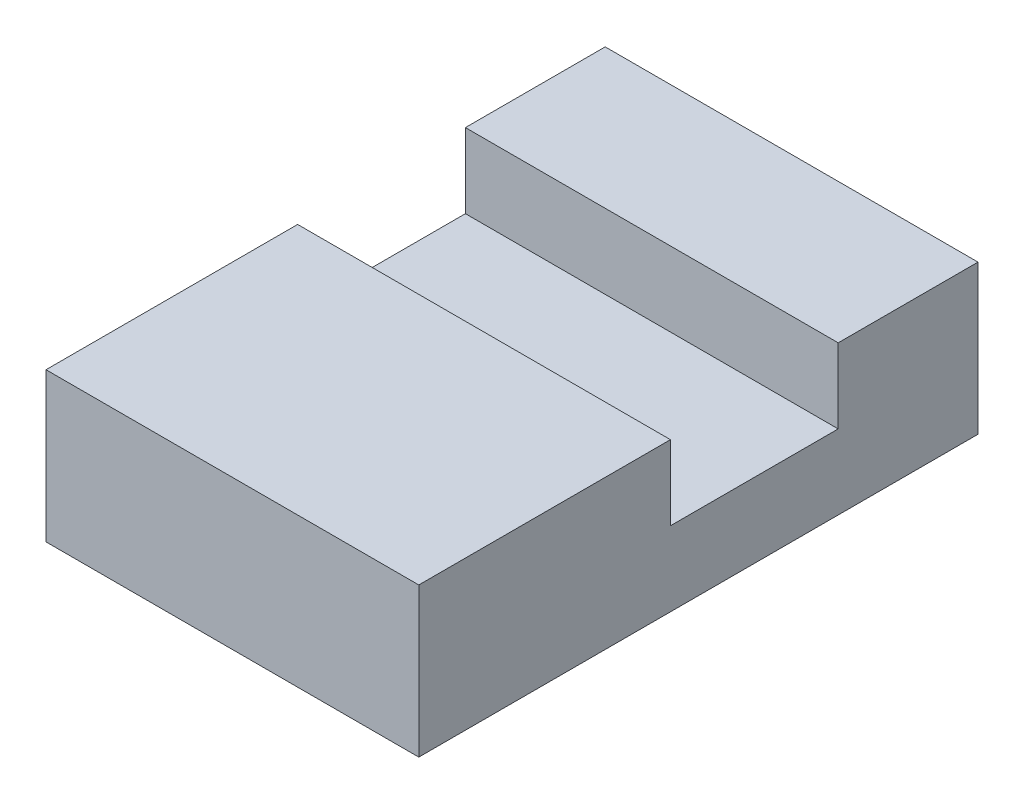
from build123d import *

# Parameters (mm, degrees)
SKETCH1_W           = 20
SKETCH1_H           = 30
BOSS_EXTRUDE1_DEPTH = 8
SKETCH3_W           = 9
SKETCH3_H           = 4
CUT_EXTRUDE1_DEPTH  = 20


with BuildPart() as part:
    # Sketch1 → Boss-Extrude1 (new body)
    with BuildSketch(Plane(origin=(0, 0, 0), x_dir=(1, 0, 0), z_dir=(0, 1, 0))):
        with Locations((-4.181818182, -5.409090909)):
            Rectangle(SKETCH1_W, SKETCH1_H)
    extrude(amount=BOSS_EXTRUDE1_DEPTH)

    # Sketch3 → Cut-Extrude1 (cut)
    with BuildSketch(Plane(origin=(5.818181818, 0, 0), x_dir=(0, 0, -1), z_dir=(1, 0, 0))):
        with Locations((-2.409090909, 6)):
            Rectangle(SKETCH3_W, SKETCH3_H)
    extrude(amount=-CUT_EXTRUDE1_DEPTH, mode=Mode.SUBTRACT)


solid = part.part
